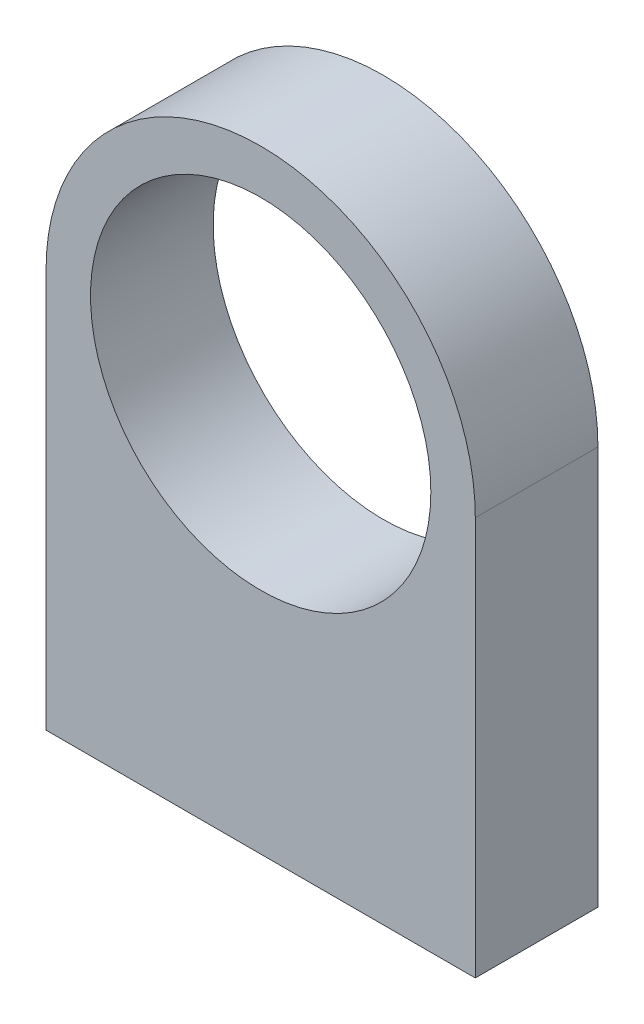
from build123d import *

# Parameters (mm, degrees)
ESQUISSE1_R             = 11.1
BOSS_EXTRU_1_DEPTH      = 8
ESQUISSE2_R             = 1.5
ENL_V_MAT_EXTRU_1_DEPTH = 15


with BuildPart() as part:
    # Esquisse1 → Boss.-Extru.1 (new body)
    with BuildSketch(Plane.XY):
        with BuildLine():
            Line((-14, 0), (-14, -26))
            Line((-14, -26), (14, -26))
            Line((14, -26), (14, 0))
            ThreePointArc((14, 0), (0, 14), (-14, 0))
        make_face()
        Circle(ESQUISSE1_R, mode=Mode.SUBTRACT)
    extrude(amount=BOSS_EXTRU_1_DEPTH)

    # Esquisse2 → Enlèv. mat.-Extru.1 (cut)
    with BuildSketch(Plane.XZ.offset(26)):
        with Locations((-10, 4)):
            Circle(ESQUISSE2_R)
        with Locations((10, 4)):
            Circle(ESQUISSE2_R)
    extrude(amount=-ENL_V_MAT_EXTRU_1_DEPTH, mode=Mode.SUBTRACT)


solid = part.part
